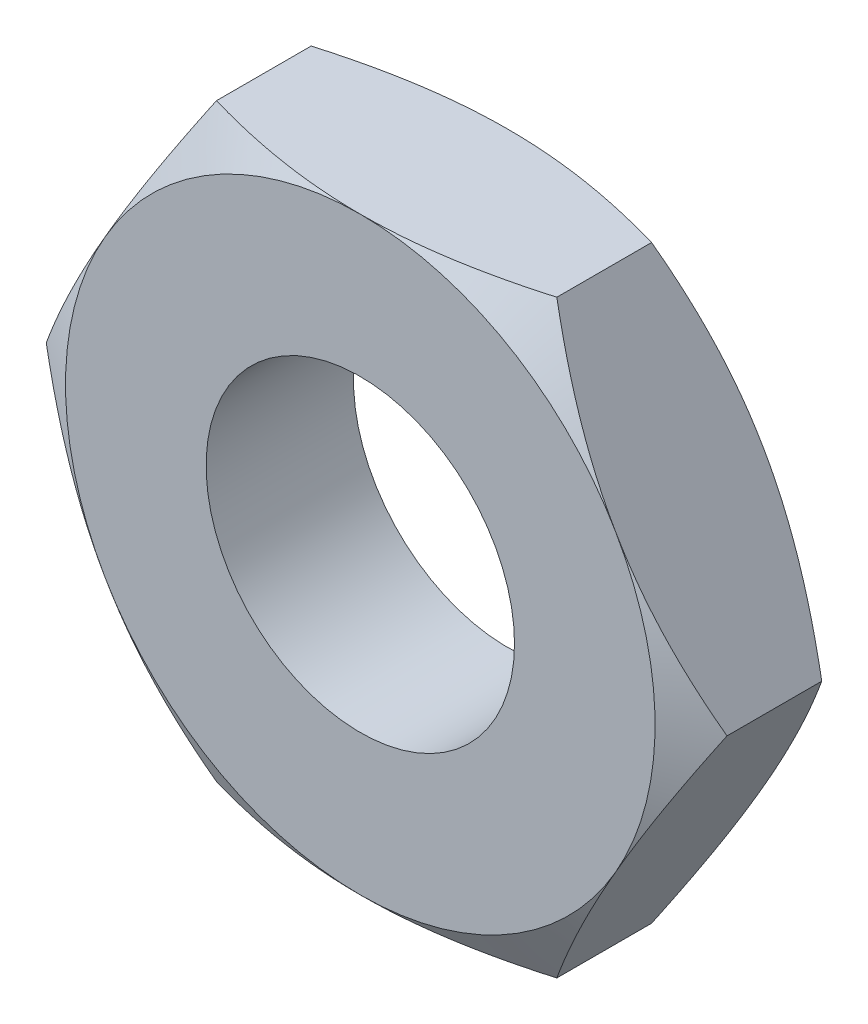
from build123d import *

# Parameters (mm, degrees)
BOSS_EXTRUDE1_DEPTH = 3.25
M8_TAPPED_HOLE1_D   = 6.8


with BuildPart() as part:
    # Sketch1 → Boss-Extrude1 (new body)
    with BuildSketch(Plane.XY):
        Polygon((3.75277675, -6.5), (7.505553499, 0), (3.75277675, 6.5), (-3.75277675, 6.5), (-7.505553499, 0), (-3.75277675, -6.5), align=None)
    extrude(amount=BOSS_EXTRUDE1_DEPTH)

    # Sketch3 → Cut-Revolve1 (revolve, cut)
    with BuildSketch(Plane(origin=(0, 0, 0), x_dir=(0, 0, -1), z_dir=(1, 0, 0))):
        Polygon((-1.711637245, 9.464642673), (0, 6.5), (0, 9.464642673), align=None)
        Polygon((-3.25, 6.5), (-3.25, 7.969336789), (-2.401678009, 7.969336789), align=None)
    revolve(axis=Axis((0, 0, 0), (0, 0, -1)), mode=Mode.SUBTRACT)

    # M8 Tapped Hole1 (through all)
    with Locations(Plane.XY.offset(3.25)):
        with Locations((0, 0)):
            Hole(M8_TAPPED_HOLE1_D / 2)


solid = part.part
